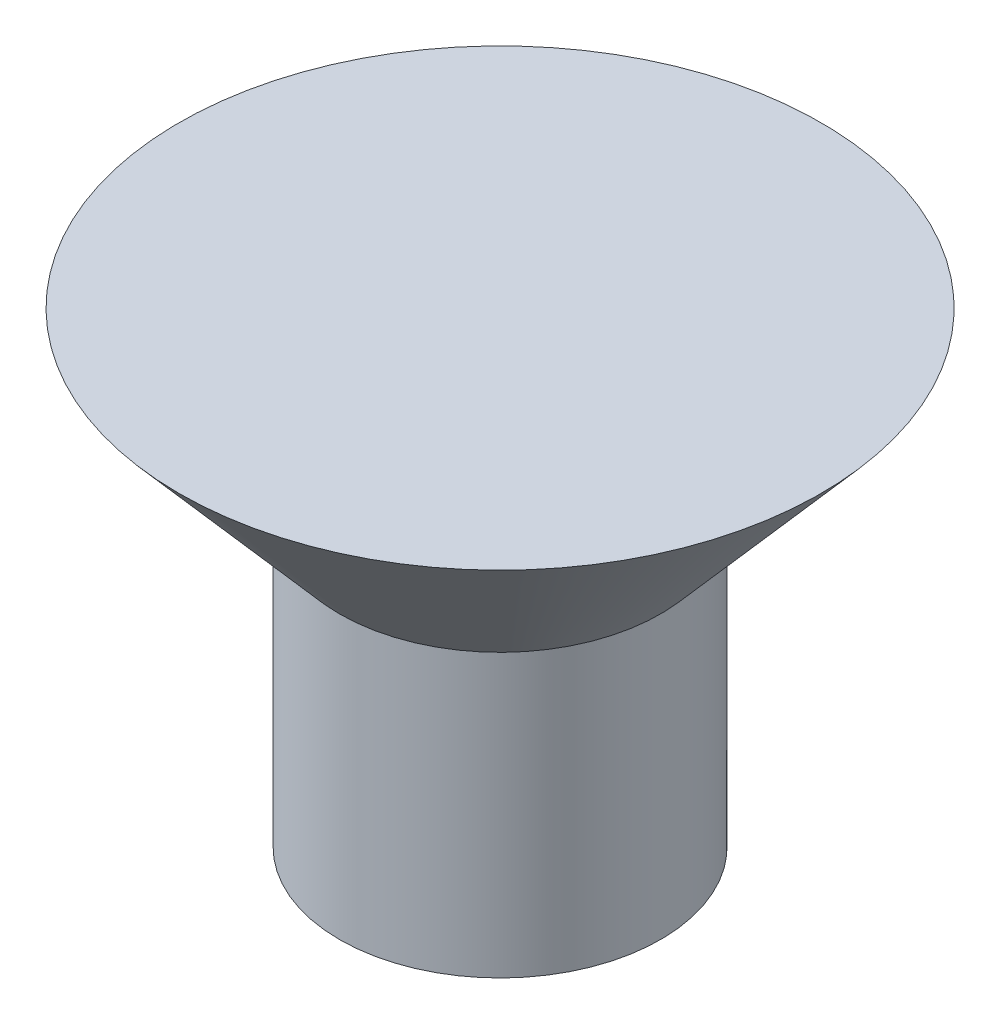
from build123d import *


with BuildPart() as part:
    # Sketch1 → Revolve1 (revolve)
    with BuildSketch(Plane(origin=(0, 0, 0), x_dir=(0, 0, -1), z_dir=(1, 0, 0)), mode=Mode.PRIVATE) as revolve1_sk:
        Polygon((0, 0), (2.1844, 0), (1.0922, -1.256432374), (1.0922, -3.175), (0, -3.175), align=None)
    revolve(revolve1_sk.sketch.rotate(Axis((0, 42.98504113, 0), (0, -1, 0)), 180), axis=Axis((0, 42.98504113, 0), (0, -1, 0)))  # turned: the seam where the file's is


solid = part.part
